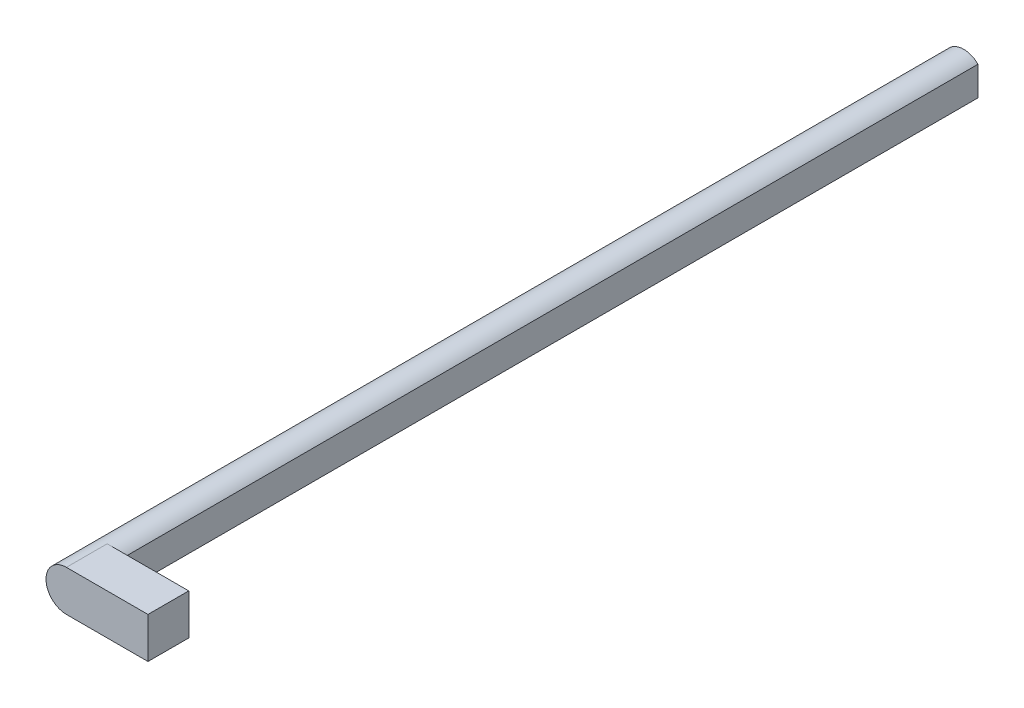
from build123d import *

# Parameters (mm, degrees)
RESSALTO_EXTRUS_O1_DEPTH = 220
ESBO_O2_W                = 10
ESBO_O2_H                = 10
RESSALTO_EXTRUS_O2_DEPTH = 20


with BuildPart() as part:
    # Esboço1 → Ressalto-extrusão1 (new body)
    with BuildSketch(Plane.XY):
        with BuildLine():
            ThreePointArc((3.5, 3.570714214), (-5, 0), (3.5, -3.570714214))
            Line((3.5, -3.570714214), (3.5, 3.570714214))
        make_face()
    extrude(amount=RESSALTO_EXTRUS_O1_DEPTH)

    # Esboço2 → Ressalto-extrusão2 (add)
    with BuildSketch(Plane(origin=(0, 0, 0), x_dir=(0, 0, -1), z_dir=(1, 0, 0))):
        with Locations((-215, 0)):
            Rectangle(ESBO_O2_W, ESBO_O2_H)
    extrude(amount=RESSALTO_EXTRUS_O2_DEPTH)


solid = part.part
